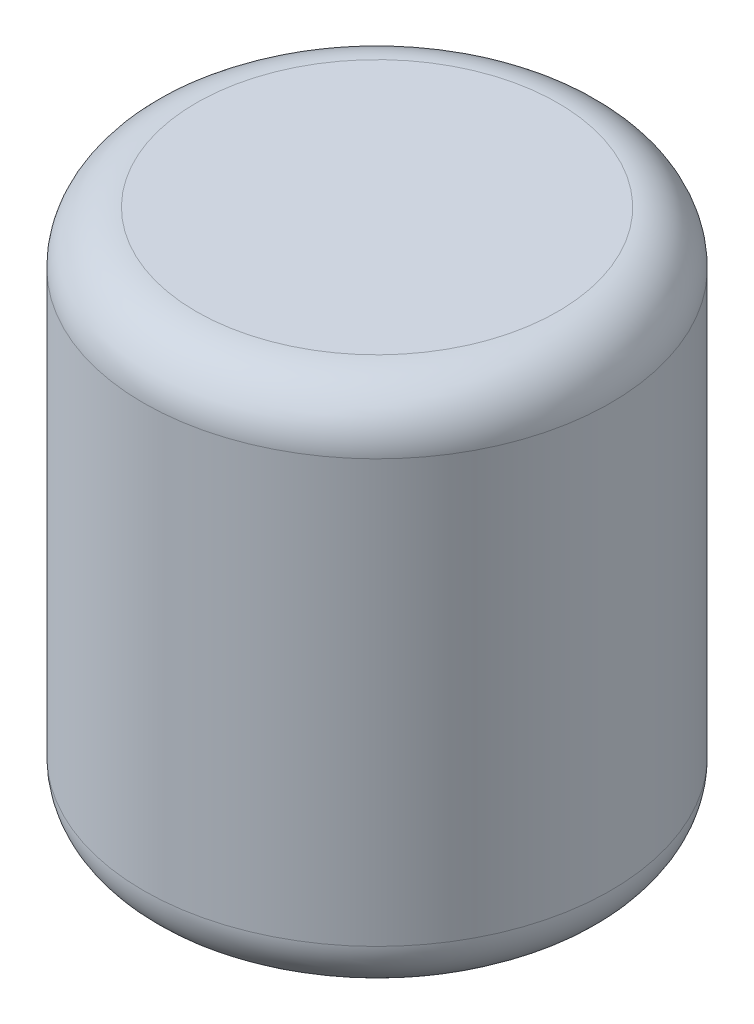
from build123d import *

# Parameters (mm, degrees)
SKETCH1_R           = 44.25
BOSS_EXTRUDE1_DEPTH = 100
FILLET1_R           = 10


with BuildPart() as part:
    # Sketch1 → Boss-Extrude1 (new body)
    with BuildSketch(Plane(origin=(0, 0, 0), x_dir=(1, 0, 0), z_dir=(0, 1, 0))):
        Circle(SKETCH1_R)
    extrude(amount=BOSS_EXTRUDE1_DEPTH)

    # Fillet1
    fillet1_edges = [part.edges().sort_by_distance(p)[0] for p in [
        (-44.25, 0, 0),
        (-44.25, 100, 0),
    ]]
    fillet(fillet1_edges, radius=FILLET1_R)


solid = part.part
